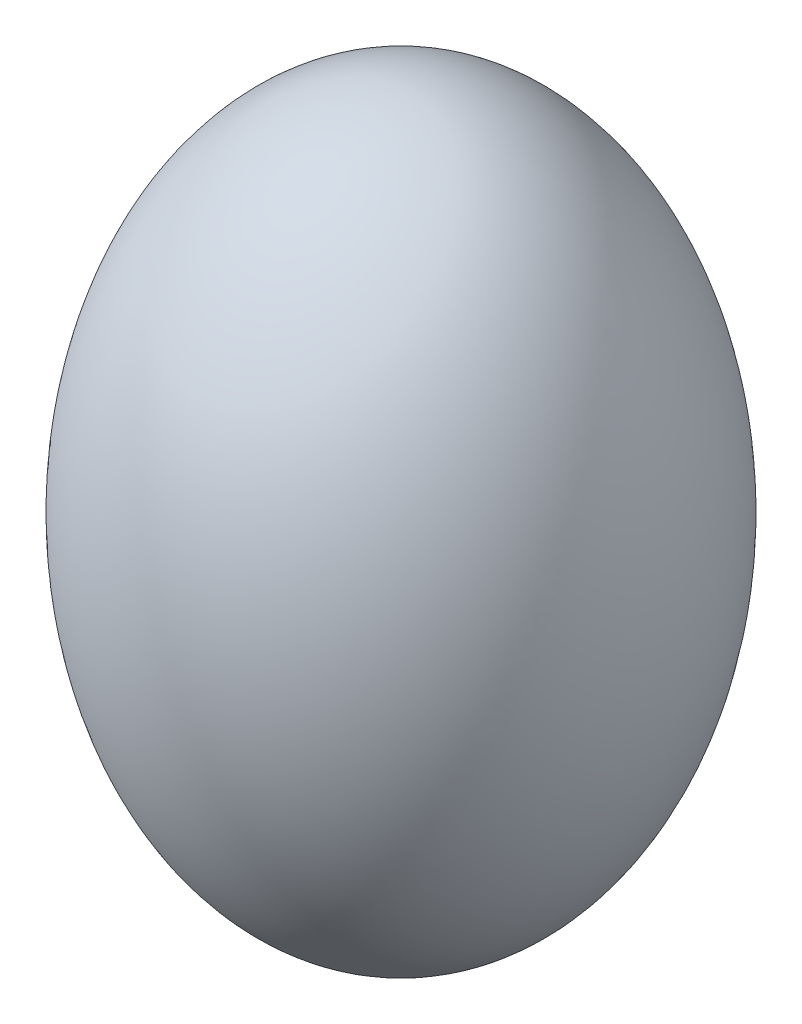
from build123d import *


with BuildPart() as part:
    # Sketch1 → Revolve1 (revolve)
    with BuildSketch(Plane.XY):
        with BuildLine():
            Line((0, 32.5), (0, -32.5))
            add(Edge.make_bspline(
                [(0, 32.5), (-22.5, 32.5), (-22.5, 0), (-22.5, -32.5), (0, -32.5)],
                knots=[0, 0, 0, 1.570796327, 1.570796327, 3.141592654, 3.141592654, 3.141592654], degree=2, weights=[1, 0.707106781, 1, 0.707106781, 1]))
        make_face()
    revolve(axis=Axis((0, 80.235419968, 0), (0, -1, 0)))


solid = part.part
